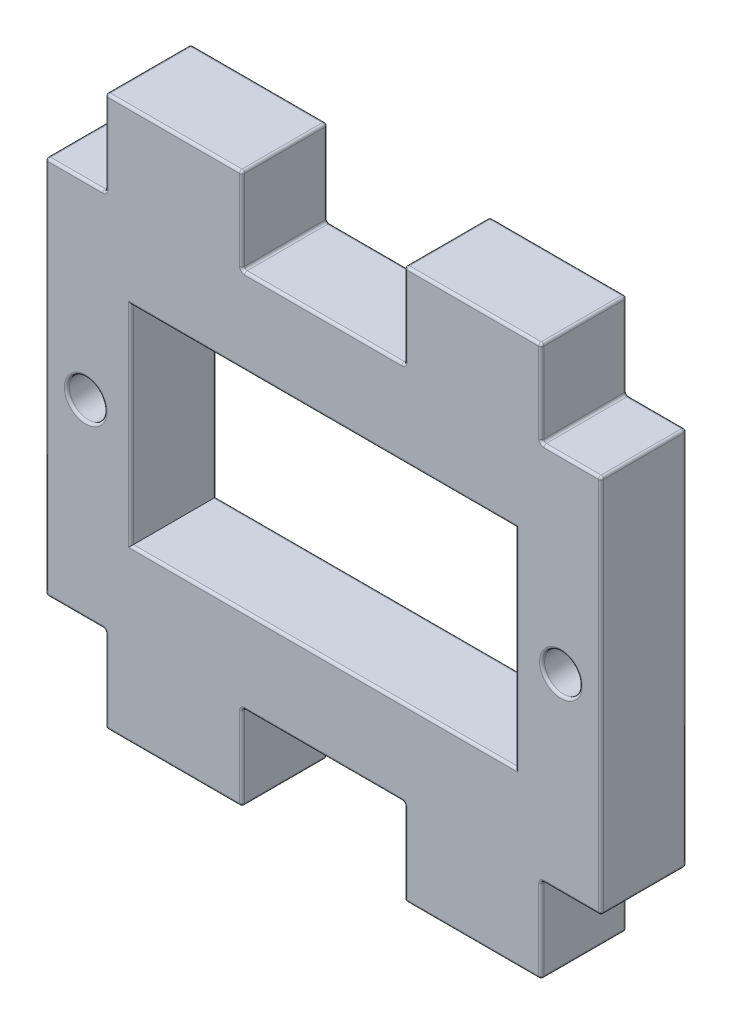
from build123d import *

# Parameters (mm, degrees)
SZKIC1_W                    = 32.5
SZKIC1_H                    = 22.2
SZKIC1_R                    = 1.1
SZKIC1_W_2                  = 22.5
SZKIC1_H_2                  = 12.2
SZKIC1_W_3                  = 8
SZKIC1_H_3                  = 5
DODANIE_WYCI_GNI_CIE1_DEPTH = 2.5
ZAOKR_GLENIE1_R             = 0.15
ZAOKR_GLENIE2_R             = 0.15


with BuildPart() as part:
    # Szkic1 → Dodanie-wyciągnięcie1 (new body, symmetric)
    with BuildSketch(Plane.XY):
        Rectangle(SZKIC1_W, SZKIC1_H)
        with Locations((-13.9, 0)):
            Circle(SZKIC1_R, mode=Mode.SUBTRACT)
        with Locations((13.9, 0)):
            Circle(SZKIC1_R, mode=Mode.SUBTRACT)
        Rectangle(SZKIC1_W_2, SZKIC1_H_2, mode=Mode.SUBTRACT)
        with Locations((-8.75, -13.6)):
            Rectangle(SZKIC1_W_3, SZKIC1_H_3)
        with Locations((8.75, -13.6)):
            Rectangle(SZKIC1_W_3, SZKIC1_H_3)
        with Locations((8.75, 13.6)):
            Rectangle(SZKIC1_W_3, SZKIC1_H_3)
        with Locations((-8.75, 13.6)):
            Rectangle(SZKIC1_W_3, SZKIC1_H_3)
    extrude(amount=DODANIE_WYCI_GNI_CIE1_DEPTH, both=True)

    # Zaokrąglenie1
    zaokr_glenie1_edges = [part.edges().sort_by_distance(p)[0] for p in [
        (-16.25, 0, 2.5),
        (-14.5, 11.1, -2.5),
        (-14.5, -11.1, 2.5),
        (-12.75, 13.6, -2.5),
        (-8.75, 16.1, -2.5),
        (-4.75, 13.6, -2.5),
        (0, 11.1, -2.5),
        (4.75, 13.6, -2.5),
        (8.75, 16.1, -2.5),
        (12.75, 13.6, -2.5),
        (14.5, 11.1, -2.5),
        (-12.75, -13.6, 2.5),
        (16.25, 0, -2.5),
        (14.5, -11.1, -2.5),
        (12.75, -13.6, -2.5),
        (8.75, -16.1, -2.5),
        (4.75, -13.6, -2.5),
        (0, -11.1, -2.5),
        (-4.75, -13.6, -2.5),
        (-8.75, -16.1, 2.5),
        (-8.75, -16.1, -2.5),
        (-12.75, -13.6, -2.5),
        (-14.5, -11.1, -2.5),
        (-16.25, 0, -2.5),
        (-4.75, -13.6, 2.5),
        (0, -11.1, 2.5),
        (4.75, -13.6, 2.5),
        (-16.25, 11.1, 0),
        (-12.75, 11.1, 0),
        (-12.75, 16.1, 0),
        (-4.75, 16.1, 0),
        (-4.75, 11.1, 0),
        (4.75, 11.1, 0),
        (4.75, 16.1, 0),
        (12.75, 16.1, 0),
        (12.75, 11.1, 0),
        (16.25, 11.1, 0),
        (16.25, -11.1, 0),
        (12.75, -11.1, 0),
        (12.75, -16.1, 0),
        (4.75, -16.1, 0),
        (4.75, -11.1, 0),
        (-4.75, -11.1, 0),
        (-4.75, -16.1, 0),
        (-12.75, -16.1, 0),
        (-12.75, -11.1, 0),
        (-16.25, -11.1, 0),
        (8.75, -16.1, 2.5),
        (12.75, -13.6, 2.5),
        (14.5, -11.1, 2.5),
        (16.25, 0, 2.5),
        (14.5, 11.1, 2.5),
        (12.75, 13.6, 2.5),
        (8.75, 16.1, 2.5),
        (4.75, 13.6, 2.5),
        (0, 11.1, 2.5),
        (-4.75, 13.6, 2.5),
        (-8.75, 16.1, 2.5),
        (-12.75, 13.6, 2.5),
        (-14.5, 11.1, 2.5),
    ]]
    fillet(zaokr_glenie1_edges, radius=ZAOKR_GLENIE1_R)

    # Zaokrąglenie2
    zaokr_glenie2_edges = [part.edges().sort_by_distance(p)[0] for p in [
        (-15, 0, 2.5),
        (12.8, 0, 2.5),
        (0, -6.1, 2.5),
        (-11.25, 0, 2.5),
        (0, 6.1, 2.5),
        (12.8, 0, -2.5),
        (-15, 0, -2.5),
        (0, 6.1, -2.5),
        (-11.25, 0, -2.5),
        (0, -6.1, -2.5),
        (11.25, 0, -2.5),
        (11.25, 0, 2.5),
    ]]
    fillet(zaokr_glenie2_edges, radius=ZAOKR_GLENIE2_R)


solid = part.part
